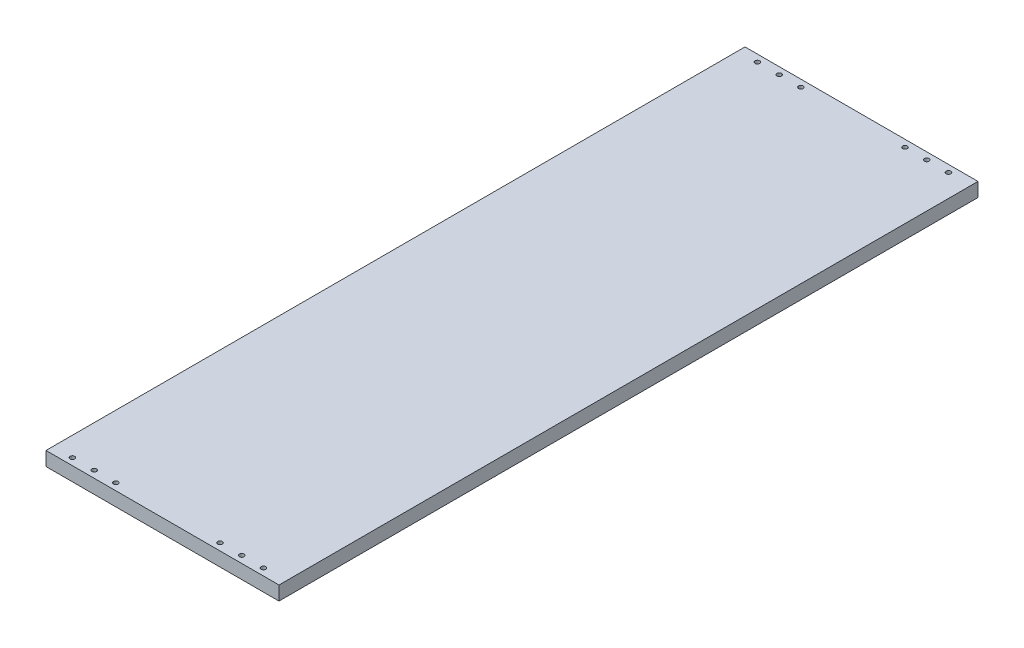
from build123d import *

# Parameters (mm, degrees)
SKETCH_2_W          = 300
SKETCH_2_H          = 900
EXTRUDE_1_DEPTH     = 18
SKETCH_3_R          = 3
CUT_EXTRUDE_1_DEPTH = 9


with BuildPart() as part:
    # Эскиз2 → Бобышка-Вытянуть1 (new body)
    with BuildSketch(Plane(origin=(0, 0, 0), x_dir=(1, 0, 0), z_dir=(0, 1, 0))):
        with Locations((150, 450)):
            Rectangle(SKETCH_2_W, SKETCH_2_H)
    extrude(amount=EXTRUDE_1_DEPTH)

    # Эскиз3 → Вырез-Вытянуть1 (cut)
    with BuildSketch(Plane(origin=(0, 18, 0), x_dir=(1, 0, 0), z_dir=(0, 1, 0))):
        with Locations((25, 9)):
            Circle(SKETCH_3_R)
        with Locations((53, 9)):
            Circle(SKETCH_3_R)
        with Locations((81, 9)):
            Circle(SKETCH_3_R)
        with Locations((215, 9)):
            Circle(SKETCH_3_R)
        with Locations((243, 9)):
            Circle(SKETCH_3_R)
        with Locations((271, 9)):
            Circle(SKETCH_3_R)
        with Locations((271, 891)):
            Circle(SKETCH_3_R)
        with Locations((243, 891)):
            Circle(SKETCH_3_R)
        with Locations((215, 891)):
            Circle(SKETCH_3_R)
        with Locations((81, 891)):
            Circle(SKETCH_3_R)
        with Locations((53, 891)):
            Circle(SKETCH_3_R)
        with Locations((25, 891)):
            Circle(SKETCH_3_R)
    extrude(amount=-CUT_EXTRUDE_1_DEPTH, mode=Mode.SUBTRACT)


solid = part.part
